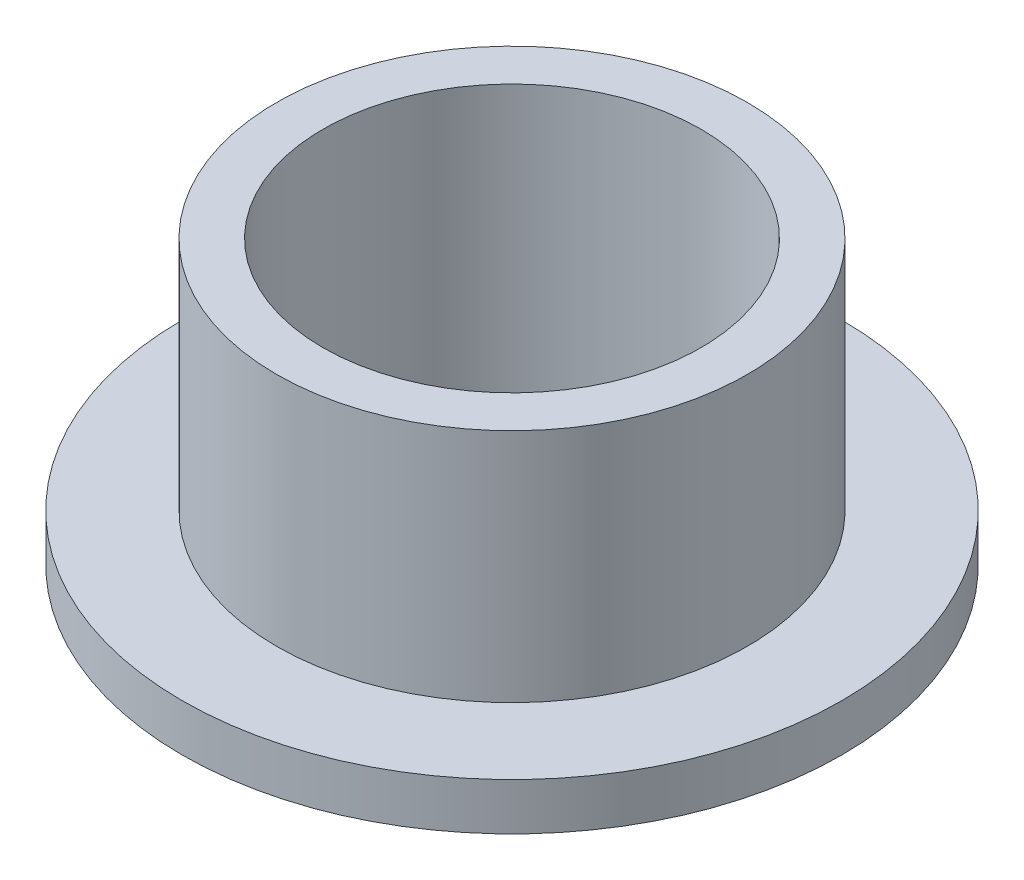
from build123d import *

# Parameters (mm, degrees)
SKETCH2_R           = 7.9375
SKETCH2_R_2         = 6.3754
BOSS_EXTRUDE1_DEPTH = 9.525
SKETCH3_R           = 11.1125
SKETCH3_R_2         = 7.9375
BOSS_EXTRUDE2_DEPTH = 1.5875


with BuildPart() as part:
    # Sketch2 → Boss-Extrude1 (new body)
    with BuildSketch(Plane(origin=(0, 0, 0), x_dir=(1, 0, 0), z_dir=(0, 1, 0))):
        Circle(SKETCH2_R)
        Circle(SKETCH2_R_2, mode=Mode.SUBTRACT)
    extrude(amount=BOSS_EXTRUDE1_DEPTH)

    # Sketch3 → Boss-Extrude2 (add)
    with BuildSketch(Plane(origin=(0, 0, 0), x_dir=(1, 0, 0), z_dir=(0, 1, 0))):
        Circle(SKETCH3_R)
        Circle(SKETCH3_R_2, mode=Mode.SUBTRACT)
    extrude(amount=BOSS_EXTRUDE2_DEPTH)


solid = part.part
